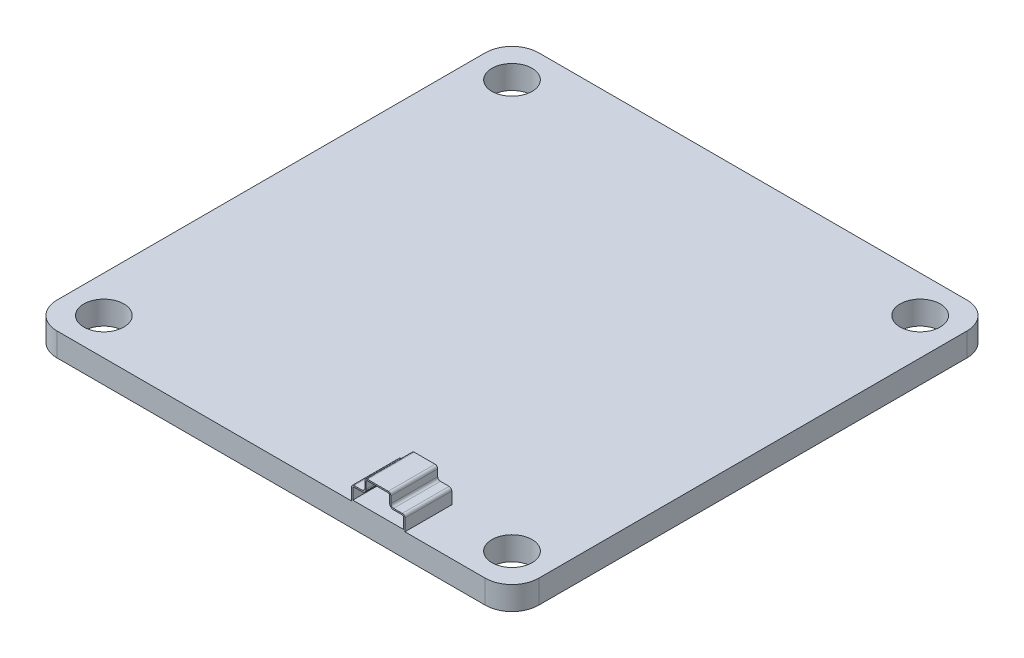
from build123d import *

# Parameters (mm, degrees)
SKETCH1_R           = 1.5
BOSS_EXTRUDE2_DEPTH = 1.75
BOSS_EXTRUDE3_DEPTH = 3
BOSS_EXTRUDE4_DEPTH = 0.5
SKETCH5_R           = 0.210276494
CUT_EXTRUDE1_DEPTH  = 0.5


with BuildPart() as part:
    # Sketch1 → Boss-Extrude2 (new body)
    with BuildSketch(Plane(origin=(0, 0, 0), x_dir=(1, 0, 0), z_dir=(0, 1, 0))):
        with BuildLine():
            Line((-16, 18), (16, 18))
            ThreePointArc((16, 18), (17.414213562, 17.414213562), (18, 16))
            Line((18, 16), (18, -16))
            ThreePointArc((18, -16), (17.414213562, -17.414213562), (16, -18))
            Line((16, -18), (-16, -18))
            ThreePointArc((-16, -18), (-17.414213562, -17.414213562), (-18, -16))
            Line((-18, -16), (-18, 16))
            ThreePointArc((-18, 16), (-17.414213562, 17.414213562), (-16, 18))
        make_face()
        with Locations((-15.25, 15.25)):
            Circle(SKETCH1_R, mode=Mode.SUBTRACT)
        with Locations((15.25, 15.25)):
            Circle(SKETCH1_R, mode=Mode.SUBTRACT)
        with Locations((15.25, -15.25)):
            Circle(SKETCH1_R, mode=Mode.SUBTRACT)
        with Locations((-15.25, -15.25)):
            Circle(SKETCH1_R, mode=Mode.SUBTRACT)
    extrude(amount=BOSS_EXTRUDE2_DEPTH)

    # Sketch3 → Boss-Extrude3 (add)
    with BuildSketch(Plane.XY.offset(18)):
        with BuildLine():
            Line((6, 1.75), (10, 1.75))
            Line((10, 1.75), (10, 2.643928524))
            ThreePointArc((10, 2.643928524), (9.941421356, 2.78534988), (9.8, 2.843928524))
            Line((9.8, 2.843928524), (9.148500836, 2.843928524))
            ThreePointArc((9.148500836, 2.843928524), (9.007079479, 2.902507168), (8.948500836, 3.043928524))
            Line((8.948500836, 3.043928524), (8.948500836, 3.55))
            ThreePointArc((8.948500836, 3.55), (8.889922192, 3.691421356), (8.748500836, 3.75))
            Line((8.748500836, 3.75), (7.202410951, 3.75))
            ThreePointArc((7.202410951, 3.75), (7.060989594, 3.691421356), (7.002410951, 3.55))
            Line((7.002410951, 3.55), (7.002410951, 3.043928524))
            ThreePointArc((7.002410951, 3.043928524), (6.943832307, 2.902507168), (6.802410951, 2.843928524))
            Line((6.802410951, 2.843928524), (6.2, 2.843928524))
            ThreePointArc((6.2, 2.843928524), (6.058578644, 2.78534988), (6, 2.643928524))
            Line((6, 2.643928524), (6, 1.75))
        make_face()
        with BuildLine():
            Line((6.1, 1.85), (6.1, 2.643928524))
            ThreePointArc((6.1, 2.643928524), (6.129289322, 2.714639202), (6.2, 2.743928524))
            Line((6.2, 2.743928524), (6.802410951, 2.743928524))
            ThreePointArc((6.802410951, 2.743928524), (7.014542985, 2.83179649), (7.102410951, 3.043928524))
            Line((7.102410951, 3.043928524), (7.102410951, 3.55))
            ThreePointArc((7.102410951, 3.55), (7.131700273, 3.620710678), (7.202410951, 3.65))
            Line((7.202410951, 3.65), (8.748500836, 3.65))
            ThreePointArc((8.748500836, 3.65), (8.819211514, 3.620710678), (8.848500836, 3.55))
            Line((8.848500836, 3.55), (8.848500836, 3.043928524))
            ThreePointArc((8.848500836, 3.043928524), (8.936368801, 2.83179649), (9.148500836, 2.743928524))
            Line((9.148500836, 2.743928524), (9.8, 2.743928524))
            ThreePointArc((9.8, 2.743928524), (9.870710678, 2.714639202), (9.9, 2.643928524))
            Line((9.9, 2.643928524), (9.9, 1.85))
            Line((9.9, 1.85), (6.1, 1.85))
        make_face(mode=Mode.SUBTRACT)
    extrude(amount=-BOSS_EXTRUDE3_DEPTH)

    # Sketch4 → Boss-Extrude4 (add)
    with BuildSketch(Plane(origin=(0, 0, 15), x_dir=(-1, 0, 0), z_dir=(0, 0, -1))):
        with BuildLine():
            Line((-6, 1.75), (-10, 1.75))
            Line((-10, 1.75), (-10, 2.643928524))
            ThreePointArc((-10, 2.643928524), (-9.941421356, 2.78534988), (-9.8, 2.843928524))
            Line((-9.8, 2.843928524), (-9.148500836, 2.843928524))
            ThreePointArc((-9.148500836, 2.843928524), (-9.007079479, 2.902507168), (-8.948500836, 3.043928524))
            Line((-8.948500836, 3.043928524), (-8.948500836, 3.55))
            ThreePointArc((-8.948500836, 3.55), (-8.889922192, 3.691421356), (-8.748500836, 3.75))
            Line((-8.748500836, 3.75), (-7.202410951, 3.75))
            ThreePointArc((-7.202410951, 3.75), (-7.060989594, 3.691421356), (-7.002410951, 3.55))
            Line((-7.002410951, 3.55), (-7.002410951, 3.043928524))
            ThreePointArc((-7.002410951, 3.043928524), (-6.943832307, 2.902507168), (-6.802410951, 2.843928524))
            Line((-6.802410951, 2.843928524), (-6.2, 2.843928524))
            ThreePointArc((-6.2, 2.843928524), (-6.058578644, 2.78534988), (-6, 2.643928524))
            Line((-6, 2.643928524), (-6, 1.75))
        make_face()
    extrude(amount=BOSS_EXTRUDE4_DEPTH)

    # Sketch5 → Cut-Extrude1 (cut)
    with BuildSketch(Plane(origin=(0, 0, 14.5), x_dir=(-1, 0, 0), z_dir=(0, 0, -1))):
        with Locations((-8.596830264, 2.577355932)):
            Circle(SKETCH5_R)
        with Locations((-7.929200441, 2.577355932)):
            Circle(SKETCH5_R)
        with Locations((-7.321447194, 2.577355932)):
            Circle(SKETCH5_R)
    extrude(amount=-CUT_EXTRUDE1_DEPTH, mode=Mode.SUBTRACT)


solid = part.part
